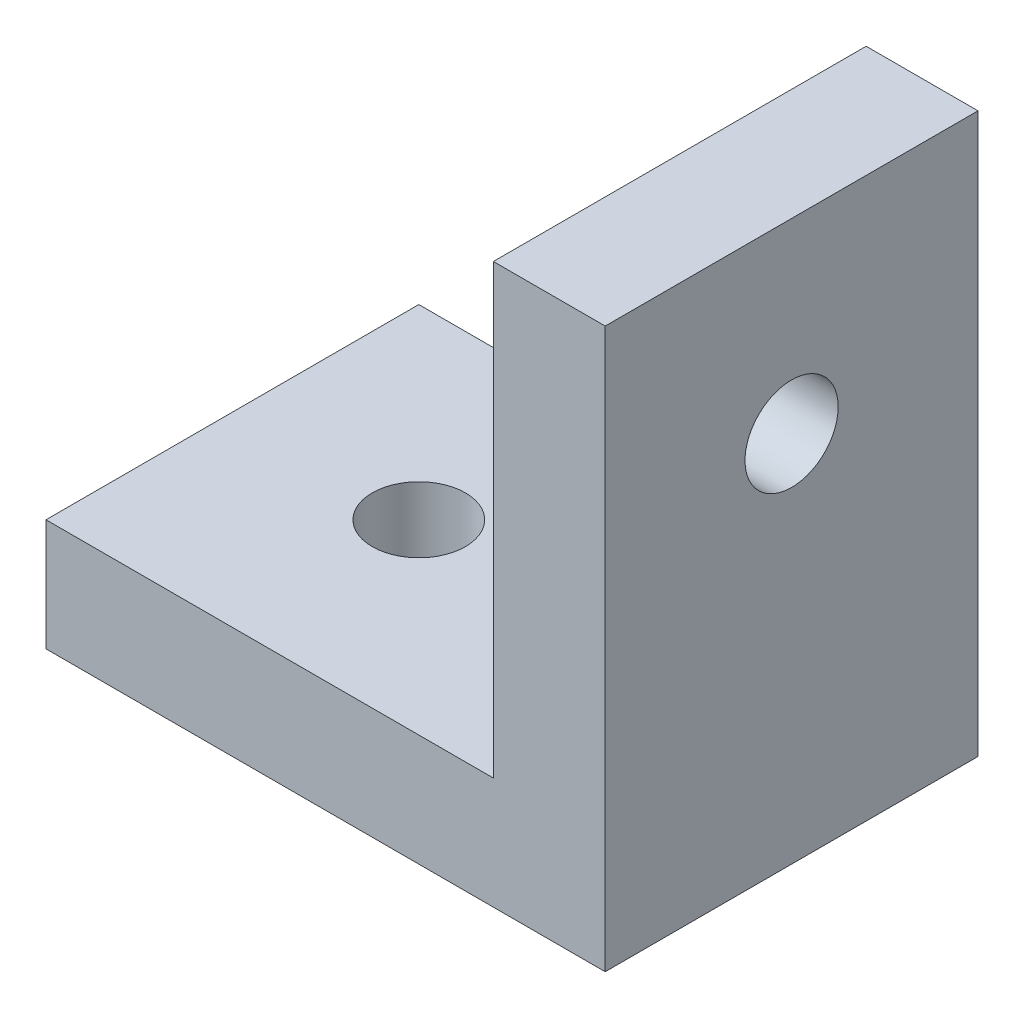
from build123d import *

# Parameters (mm, degrees)
EXTRUDE_1_DEPTH             = 10
HOLE_WIZARD_2_5_2_5_1_D     = 2.5
HOLE_WIZARD_2_5_2_5_1_DEPTH = 15
HOLE_WIZARD_2_5_2_5_2_D     = 2.5
HOLE_WIZARD_2_5_2_5_2_DEPTH = 15


with BuildPart() as part:
    # 草圖1 → 填料-伸長1 (new body)
    with BuildSketch(Plane(origin=(0, 0, -5), x_dir=(-1, 0, 0), z_dir=(0, 0, -1))):
        Polygon((-7.5, 0), (7.5, 0), (7.5, 3), (-4.5, 3), (-4.5, 15), (-7.5, 15), align=None)
    extrude(amount=-EXTRUDE_1_DEPTH)

    # Ø2.5 (2.5) 直徑孔1
    with Locations(Plane(origin=(7.5, 0, 0), x_dir=(0, 0, -1), z_dir=(1, 0, 0))):
        with Locations((0, 10)):
            Hole(HOLE_WIZARD_2_5_2_5_1_D / 2, depth=HOLE_WIZARD_2_5_2_5_1_DEPTH)

    # Ø2.5 (2.5) 直徑孔2
    with Locations(Plane(origin=(0, 0, 0), x_dir=(-1, 0, 0), z_dir=(0, -1, 0))):
        with Locations((2.5, 0)):
            Hole(HOLE_WIZARD_2_5_2_5_2_D / 2, depth=HOLE_WIZARD_2_5_2_5_2_DEPTH)


solid = part.part
